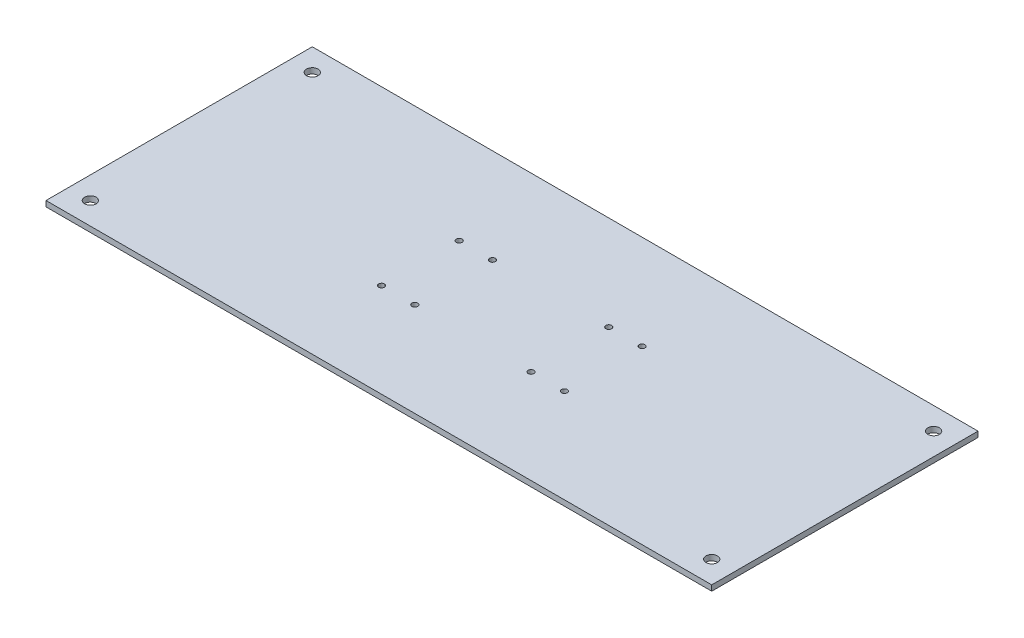
from build123d import *

# Parameters (mm, degrees)
SKETCH1_W           = 381
SKETCH1_H           = 152.4
SKETCH1_R           = 3.302
SKETCH1_R_2         = 1.651
BOSS_EXTRUDE1_DEPTH = 3.175


with BuildPart() as part:
    # Sketch1 → Boss-Extrude1 (new body)
    with BuildSketch(Plane(origin=(0, 0, 0), x_dir=(1, 0, 0), z_dir=(0, 1, 0))):
        Rectangle(SKETCH1_W, SKETCH1_H)
        with Locations((-177.8, 63.5)):
            Circle(SKETCH1_R, mode=Mode.SUBTRACT)
        with Locations((177.8, 63.5)):
            Circle(SKETCH1_R, mode=Mode.SUBTRACT)
        with Locations((-177.8, -63.5)):
            Circle(SKETCH1_R, mode=Mode.SUBTRACT)
        with Locations((177.8, -63.5)):
            Circle(SKETCH1_R, mode=Mode.SUBTRACT)
        with Locations((-52.324, 22.098)):
            Circle(SKETCH1_R_2, mode=Mode.SUBTRACT)
        with Locations((-52.324, -22.352)):
            Circle(SKETCH1_R_2, mode=Mode.SUBTRACT)
        with Locations((-33.274, 22.098)):
            Circle(SKETCH1_R_2, mode=Mode.SUBTRACT)
        with Locations((-33.274, -22.352)):
            Circle(SKETCH1_R_2, mode=Mode.SUBTRACT)
        with Locations((33.274, 22.098)):
            Circle(SKETCH1_R_2, mode=Mode.SUBTRACT)
        with Locations((33.274, -22.352)):
            Circle(SKETCH1_R_2, mode=Mode.SUBTRACT)
        with Locations((52.324, -22.352)):
            Circle(SKETCH1_R_2, mode=Mode.SUBTRACT)
        with Locations((52.324, 22.098)):
            Circle(SKETCH1_R_2, mode=Mode.SUBTRACT)
    extrude(amount=BOSS_EXTRUDE1_DEPTH)


solid = part.part
